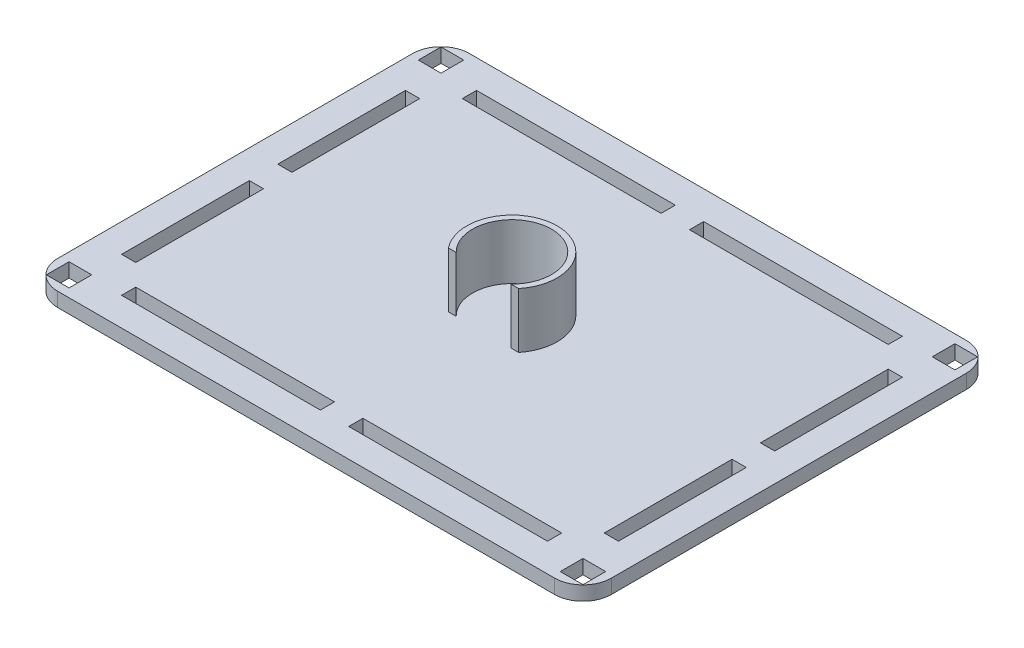
from build123d import *

# Parameters (mm, degrees)
BOSS_EXTRUDE2_DEPTH = 5
SKETCH5_W           = 5
SKETCH5_H           = 45
SKETCH5_W_2         = 70
SKETCH5_H_2         = 5
CUT_EXTRUDE5_DEPTH  = 6
BOSS_EXTRUDE3_DEPTH = 19.5
FILLET1_R           = 10
CUT_EXTRUDE6_DEPTH  = 5


with BuildPart() as part:
    # Sketch4 → Boss-Extrude2 (new body)
    with BuildSketch(Plane(origin=(0, 0, 0), x_dir=(1, 0, 0), z_dir=(0, 1, 0))):
        Polygon((0, 0), (-97.5, 72.5), (-97.5, -72.5), align=None)
        Polygon((0, 0), (-97.5, -72.5), (97.5, -72.5), align=None)
        Polygon((97.5, 72.5), (-97.5, 72.5), (0, 0), align=None)
        Polygon((97.5, -72.5), (97.5, 72.5), (0, 0), align=None)
    extrude(amount=BOSS_EXTRUDE2_DEPTH)

    # Sketch5 → Cut-Extrude5 (cut, through all)
    with BuildSketch(Plane(origin=(0, 5, 0), x_dir=(1, 0, 0), z_dir=(0, 1, 0))):
        with Locations((-85, 27.5)):
            Rectangle(SKETCH5_W, SKETCH5_H)
        with Locations((-85, -27.5)):
            Rectangle(SKETCH5_W, SKETCH5_H)
        with Locations((-40, -60)):
            Rectangle(SKETCH5_W_2, SKETCH5_H_2)
        with Locations((40, -60)):
            Rectangle(SKETCH5_W_2, SKETCH5_H_2)
        with Locations((85, -27.5)):
            Rectangle(SKETCH5_W, SKETCH5_H)
        with Locations((85, 27.5)):
            Rectangle(SKETCH5_W, SKETCH5_H)
        with Locations((40, 60)):
            Rectangle(SKETCH5_W_2, SKETCH5_H_2)
        with Locations((-40, 60)):
            Rectangle(SKETCH5_W_2, SKETCH5_H_2)
    extrude(amount=-CUT_EXTRUDE5_DEPTH, mode=Mode.SUBTRACT)

    # Sketch6 → Boss-Extrude3 (add)
    with BuildSketch(Plane(origin=(0, 5, 0), x_dir=(1, 0, 0), z_dir=(0, 1, 0))):
        with BuildLine():
            ThreePointArc((15.9, 0), (-5.30377301, 14.989329267), (-12.361634196, -10))
            Line((-12.361634196, -10), (-9.654532614, -10))
            ThreePointArc((-9.654532614, -10), (-5.431942409, 12.794686462), (13.9, 0))
            ThreePointArc((13.9, 0), (12.794686462, -5.431942409), (9.654532614, -10))
            Line((9.654532614, -10), (12.361634196, -10))
            ThreePointArc((12.361634196, -10), (14.989329267, -5.30377301), (15.9, 0))
        make_face()
    extrude(amount=BOSS_EXTRUDE3_DEPTH)

    # Fillet1
    fillet1_edges = [part.edges().sort_by_distance(p)[0] for p in [
        (-97.5, 2.5, 72.5),
        (-97.5, 2.5, -72.5),
        (97.5, 2.5, -72.5),
        (97.5, 2.5, 72.5),
    ]]
    fillet(fillet1_edges, radius=FILLET1_R)

    # Sketch7 → Cut-Extrude6 (cut)
    with BuildSketch(Plane(origin=(0, 5, 0), x_dir=(1, 0, 0), z_dir=(0, 1, 0))):
        Polygon((-86.5, 69.5), (-94.5, 69.5), (-86.5, 63.616402116), align=None)
        Polygon((-94.5, 69.5), (-94.5, 61.5), (-86.5, 61.5), (-86.5, 63.616402116), align=None)
        Polygon((-86.5, -61.5), (-94.5, -61.5), (-94.5, -69.5), (-86.5, -63.616402116), align=None)
        Polygon((-86.5, -63.616402116), (-94.5, -69.5), (-86.5, -69.5), align=None)
        Polygon((86.5, -63.616402116), (86.5, -69.5), (94.5, -69.5), align=None)
        Polygon((86.5, -61.5), (86.5, -63.616402116), (94.5, -69.5), (94.5, -61.5), align=None)
        Polygon((86.5, 69.5), (86.5, 63.616402116), (94.5, 69.5), align=None)
        Polygon((94.5, 69.5), (86.5, 63.616402116), (86.5, 61.5), (94.5, 61.5), align=None)
    extrude(amount=-CUT_EXTRUDE6_DEPTH, mode=Mode.SUBTRACT)


solid = part.part
